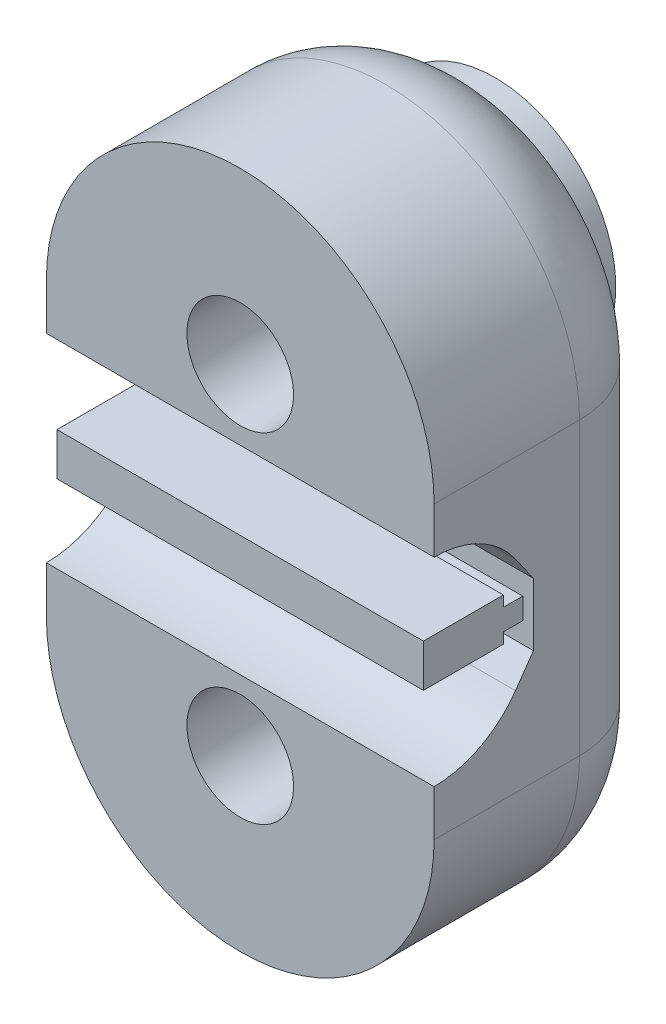
from build123d import *

# Parameters (mm, degrees)
BOSS_EXTRUDE1_DEPTH      = 10
CUT_EXTRUDE3_DEPTH       = 17
SKETCH5_R                = 2.2
CUT_EXTRUDE4_DEPTH       = 11
FILLET2_R                = 4
SKETCH7_R                = 5
SKETCH7_R_2              = 2.2
BOSS_EXTRUDE2_DEPTH      = 0.5
BOSS_EXTRUDE2_DEPTH_BACK = 3
SKETCH8_W                = 15.12
SKETCH8_H                = 0.88
BOSS_EXTRUDE3_DEPTH      = 0.8
SKETCH9_W                = 15.12
SKETCH9_H                = 1.76
BOSS_EXTRUDE4_DEPTH      = 3.3


with BuildPart() as part:
    # Sketch1 → Boss-Extrude1 (new body)
    with BuildSketch(Plane.XY):
        with BuildLine():
            Line((-5, 7.5), (-5, -4.5))
            ThreePointArc((-5, -4.5), (3, -12.5), (11, -4.5))
            Line((11, -4.5), (11, 7.5))
            ThreePointArc((11, 7.5), (3, 15.5), (-5, 7.5))
        make_face()
    extrude(amount=BOSS_EXTRUDE1_DEPTH)

    # Sketch4 → Cut-Extrude3 (cut, through all)
    with BuildSketch(Plane.ZY.offset(5)):
        with BuildLine():
            Line((6.641476618, -0.851663389), (5.9, 0.207274966))
            Line((5.9, 0.207274966), (5.9, 2.792725034))
            Line((5.9, 2.792725034), (6.641476618, 3.851663389))
            ThreePointArc((6.641476618, 3.851663389), (14.1, 1.5), (6.641476618, -0.851663389))
        make_face()
    extrude(amount=-CUT_EXTRUDE3_DEPTH, mode=Mode.SUBTRACT)

    # Sketch5 → Cut-Extrude4 (cut, through all)
    with BuildSketch(Plane(origin=(0, 0, 0), x_dir=(-1, 0, 0), z_dir=(0, 0, -1))):
        with Locations((-3, 8.5)):
            Circle(SKETCH5_R)
        with Locations((-3, -5.5)):
            Circle(SKETCH5_R)
    extrude(amount=-CUT_EXTRUDE4_DEPTH, mode=Mode.SUBTRACT)

    # Fillet2
    fillet2_edges = [part.edges().sort_by_distance(p)[0] for p in [
        (-5, 1.5, 0),
        (3, 15.5, 0),
        (11, 1.5, 0),
        (3, -12.5, 0),
    ]]
    fillet(fillet2_edges, radius=FILLET2_R)

    # Sketch7 → Boss-Extrude2 (add, two sides)
    with BuildSketch(Plane(origin=(0, 0, 0), x_dir=(-1, 0, 0), z_dir=(0, 0, -1))) as boss_extrude2_sk:
        with Locations((-3, 8.5)):
            Circle(SKETCH7_R)
        with Locations((-3, 8.5)):
            Circle(SKETCH7_R_2, mode=Mode.SUBTRACT)
        with Locations((-3, -5.5)):
            Circle(SKETCH7_R)
        with Locations((-3, -5.5)):
            Circle(SKETCH7_R_2, mode=Mode.SUBTRACT)
    extrude(amount=BOSS_EXTRUDE2_DEPTH)
    extrude(boss_extrude2_sk.sketch, amount=-BOSS_EXTRUDE2_DEPTH_BACK)

    # Sketch8 → Boss-Extrude3 (add)
    with BuildSketch(Plane.XY.offset(5.9)):
        with Locations((3, 1.5)):
            Rectangle(SKETCH8_W, SKETCH8_H)
    extrude(amount=BOSS_EXTRUDE3_DEPTH)

    # Sketch9 → Boss-Extrude4 (add)
    with BuildSketch(Plane.XY.offset(6.7)):
        with Locations((3, 1.5)):
            Rectangle(SKETCH9_W, SKETCH9_H)
    extrude(amount=BOSS_EXTRUDE4_DEPTH)


solid = part.part
